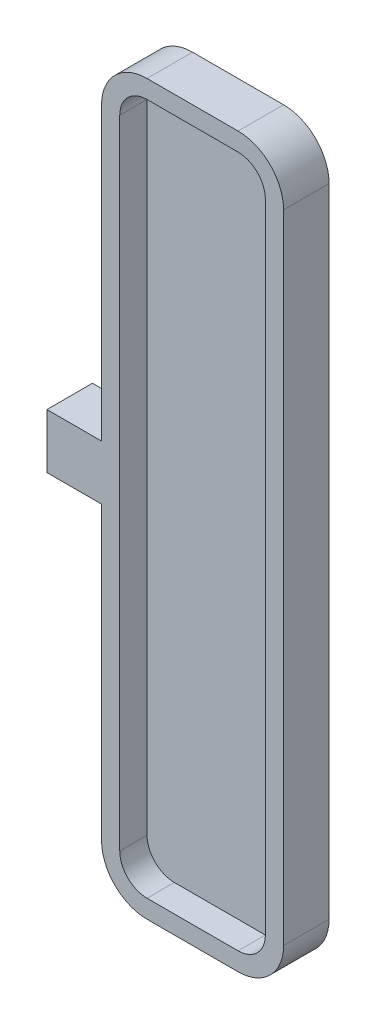
from build123d import *

# Parameters (mm, degrees)
SKETCH1_W           = 20
SKETCH1_H           = 80
BOSS_EXTRUDE1_DEPTH = 5
FILLET1_R           = 5
SHELL1_T            = -2
SKETCH3_W           = 5
SKETCH3_H           = 6
BOSS_EXTRUDE3_DEPTH = 6
SKETCH4_R           = 1.425
CUT_EXTRUDE1_DEPTH  = 4


with BuildPart() as part:
    # Sketch1 → Boss-Extrude1 (new body)
    with BuildSketch(Plane.XY):
        Rectangle(SKETCH1_W, SKETCH1_H)
    extrude(amount=BOSS_EXTRUDE1_DEPTH)

    # Fillet1
    fillet1_edges = [part.edges().sort_by_distance(p)[0] for p in [
        (-10, 40, 2.5),
        (10, 40, 2.5),
        (10, -40, 2.5),
        (-10, -40, 2.5),
    ]]
    fillet(fillet1_edges, radius=FILLET1_R)

    # Shell1
    shell1_openings = [part.faces().sort_by_distance(p)[0] for p in [
        (0, 0, 5),
    ]]
    offset(amount=SHELL1_T, openings=shell1_openings, kind=Kind.INTERSECTION)

    # Sketch3 → Boss-Extrude3 (add)
    with BuildSketch(Plane.ZY.offset(10)):
        with Locations((2.5, 0)):
            Rectangle(SKETCH3_W, SKETCH3_H)
    extrude(amount=BOSS_EXTRUDE3_DEPTH)

    # Sketch4 → Cut-Extrude1 (cut)
    with BuildSketch(Plane.ZY.offset(16)):
        with Locations((2.5, 0)):
            Circle(SKETCH4_R)
    extrude(amount=-CUT_EXTRUDE1_DEPTH, mode=Mode.SUBTRACT)


solid = part.part
